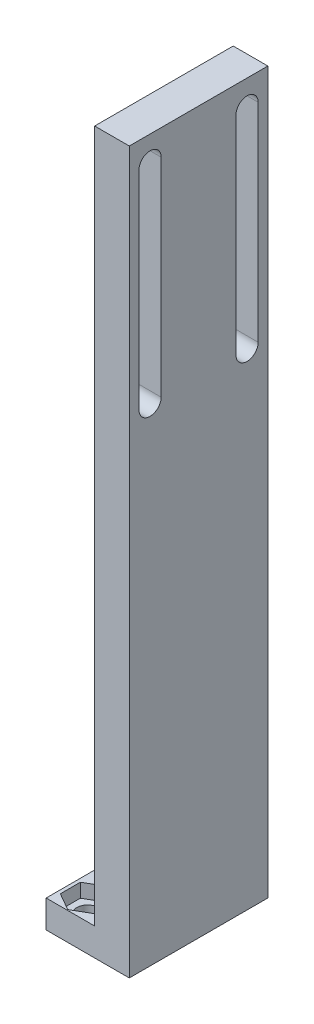
from build123d import *

# Parameters (mm, degrees)
SKETCH1_W           = 12
SKETCH1_H           = 20
SKETCH1_R           = 1.6
BOSS_EXTRUDE1_DEPTH = 4
SKETCH18_W          = 5
SKETCH18_H          = 20
BOSS_EXTRUDE3_DEPTH = 100
CUT_EXTRUDE4_DEPTH  = 2
CUT_EXTRUDE5_DEPTH  = 5


with BuildPart() as part:
    # Sketch1 → Boss-Extrude1 (new body)
    with BuildSketch(Plane(origin=(0, 0, 0), x_dir=(1, 0, 0), z_dir=(0, 1, 0))):
        Rectangle(SKETCH1_W, SKETCH1_H)
        with Locations((-3, 7)):
            Circle(SKETCH1_R, mode=Mode.SUBTRACT)
        with Locations((-3, -7)):
            Circle(SKETCH1_R, mode=Mode.SUBTRACT)
    extrude(amount=BOSS_EXTRUDE1_DEPTH)

    # Sketch18 → Boss-Extrude3 (add)
    with BuildSketch(Plane(origin=(0, 4, 0), x_dir=(1, 0, 0), z_dir=(0, 1, 0))):
        with Locations((3.5, 0)):
            Rectangle(SKETCH18_W, SKETCH18_H)
    extrude(amount=BOSS_EXTRUDE3_DEPTH)

    # Sketch20 → Cut-Extrude4 (cut)
    with BuildSketch(Plane(origin=(0, 4, 0), x_dir=(1, 0, 0), z_dir=(0, 1, 0))):
        Polygon((-0.494371857, 5.523768453), (-0.468731907, 8.431821851), (-2.97436005, 9.908053397), (-5.505628143, 8.476231547), (-5.531268093, 5.568178149), (-3.02563995, 4.091946603), align=None)
        Polygon((-0.494371857, -8.441467238), (-0.498838682, -5.550795995), (-3.004466825, -4.109328757), (-5.505628143, -5.558532762), (-5.501161318, -8.449204005), (-2.995533175, -9.890671243), align=None)
    extrude(amount=-CUT_EXTRUDE4_DEPTH, mode=Mode.SUBTRACT)

    # Sketch21 → Cut-Extrude5 (cut)
    with BuildSketch(Plane(origin=(6, 0, 0), x_dir=(0, 0, -1), z_dir=(1, 0, 0))):
        with BuildLine():
            Line((-5.4, 100.304925489), (-5.4, 70.304925489))
            ThreePointArc((-5.4, 70.304925489), (-7, 68.704925489), (-8.6, 70.304925489))
            Line((-8.6, 70.304925489), (-8.6, 100.304925489))
            ThreePointArc((-8.6, 100.304925489), (-7, 101.904925489), (-5.4, 100.304925489))
        make_face()
        with BuildLine():
            Line((8.6, 100.170306459), (8.6, 70.170306459))
            ThreePointArc((8.6, 70.170306459), (7, 68.570306459), (5.4, 70.170306459))
            Line((5.4, 70.170306459), (5.4, 100.170306459))
            ThreePointArc((5.4, 100.170306459), (7, 101.770306459), (8.6, 100.170306459))
        make_face()
    extrude(amount=-CUT_EXTRUDE5_DEPTH, mode=Mode.SUBTRACT)


solid = part.part
